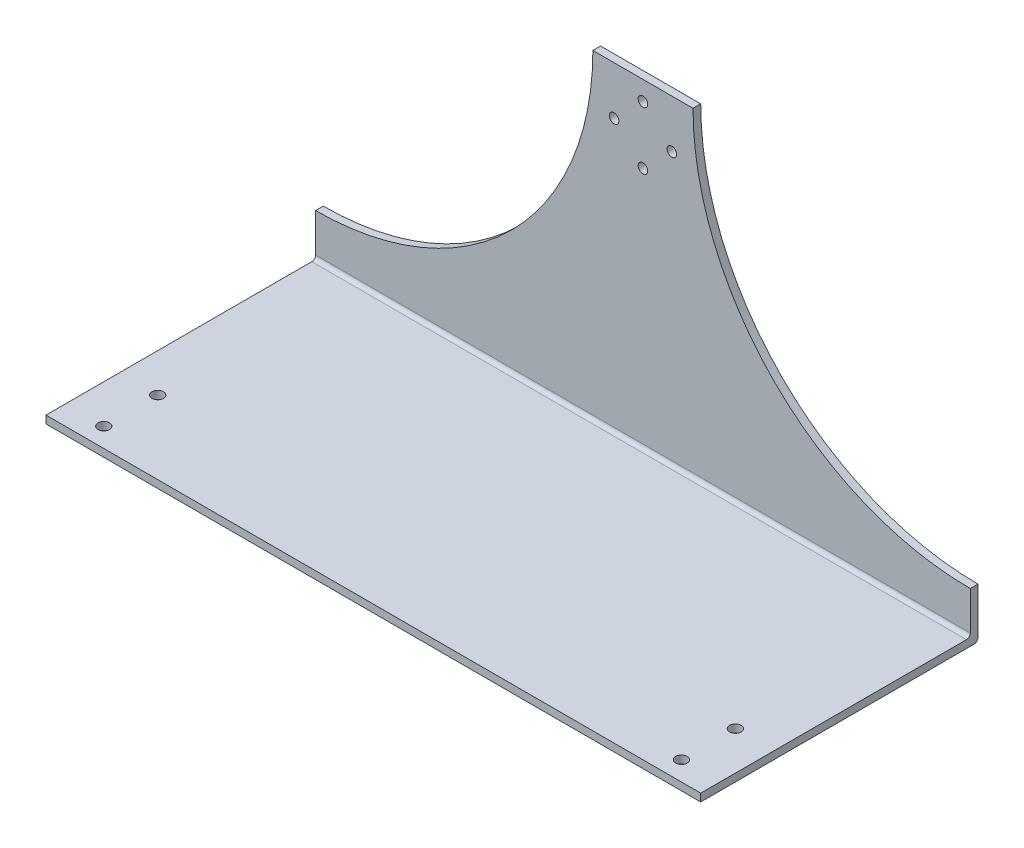
from build123d import *

# Parameters (mm, degrees)
SKETCH1_W               = 170
SKETCH1_H               = 70
BOSS_EXTRUDE1_DEPTH     = 2
CUT_EXTRUDE1_DEPTH      = 22
CUT_EXTRUDE1_DEPTH_BACK = 22
SKETCH2_R               = 1.5
SKETCH4_W               = 170
SKETCH4_H               = 85
BOSS_EXTRUDE2_DEPTH     = 2
FILLET2_R               = 1
FILLET3_R               = 1
CUT_EXTRUDE3_DEPTH      = 12
CUT_EXTRUDE3_DEPTH_BACK = 12
SKETCH6_R               = 1.25
CUT_EXTRUDE4_DEPTH      = 12
CUT_EXTRUDE4_DEPTH_BACK = 12
SKETCH5_R               = 72


with BuildPart() as part:
    # Sketch1 → Boss-Extrude1 (new body)
    with BuildSketch(Plane(origin=(0, 0, 0), x_dir=(1, 0, 0), z_dir=(0, 1, 0))):
        with Locations((-0.557701395, -36.216789823)):
            Rectangle(SKETCH1_W, SKETCH1_H)
    extrude(amount=BOSS_EXTRUDE1_DEPTH)

    # Sketch2 → Cut-Extrude1 (cut, two sides: drawn at the far end of the back side and taken through both)
    with BuildSketch(Plane(origin=(0, 2, 0), x_dir=(1, 0, 0), z_dir=(0, 1, 0)).offset(-CUT_EXTRUDE1_DEPTH_BACK)):
        with Locations((-75.557701395, -52.216789823)):
            Circle(SKETCH2_R)
        with Locations((-75.557701395, -66.216789823)):
            Circle(SKETCH2_R)
        with Locations((74.442298605, -52.216789823)):
            Circle(SKETCH2_R)
        with Locations((74.442298605, -66.216789823)):
            Circle(SKETCH2_R)
    extrude(amount=CUT_EXTRUDE1_DEPTH + CUT_EXTRUDE1_DEPTH_BACK, mode=Mode.SUBTRACT)

    # Sketch4 → Boss-Extrude2 (add)
    with BuildSketch(Plane(origin=(0, 0, 1.216789823), x_dir=(-1, 0, 0), z_dir=(0, 0, -1))):
        with Locations((0.557701395, 42.5)):
            Rectangle(SKETCH4_W, SKETCH4_H)
    extrude(amount=BOSS_EXTRUDE2_DEPTH)

    # Fillet2
    fillet2_edges = [part.edges().sort_by_distance(p)[0] for p in [
        (-0.557701395, 0, -0.783210177),
    ]]
    fillet(fillet2_edges, radius=FILLET2_R)

    # Fillet3
    fillet3_edges = [part.edges().sort_by_distance(p)[0] for p in [
        (-0.557701395, 2, 1.216789823),
    ]]
    fillet(fillet3_edges, radius=FILLET3_R)

    # Sketch6 → Cut-Extrude3 (cut, two sides: drawn at the far end of the back side and taken through both)
    with BuildSketch(Plane.XY.offset(1.216789823).offset(-CUT_EXTRUDE3_DEPTH_BACK)):
        with Locations((-0.557701395, 80)):
            Circle(SKETCH6_R)
        with Locations((-0.557701395, 65)):
            Circle(SKETCH6_R)
        with Locations((6.942298605, 72.5)):
            Circle(SKETCH6_R)
        with Locations((-8.057701395, 72.5)):
            Circle(SKETCH6_R)
    extrude(amount=CUT_EXTRUDE3_DEPTH + CUT_EXTRUDE3_DEPTH_BACK, mode=Mode.SUBTRACT)

    # Sketch5 → Cut-Extrude4 (cut, two sides: drawn at the far end of the back side and taken through both)
    with BuildSketch(Plane.XY.offset(1.216789823).offset(-CUT_EXTRUDE4_DEPTH_BACK)):
        with Locations((-85.557701395, 85)):
            Circle(SKETCH5_R)
        with Locations((84.442298605, 85)):
            Circle(SKETCH5_R)
    extrude(amount=CUT_EXTRUDE4_DEPTH + CUT_EXTRUDE4_DEPTH_BACK, mode=Mode.SUBTRACT)


solid = part.part
